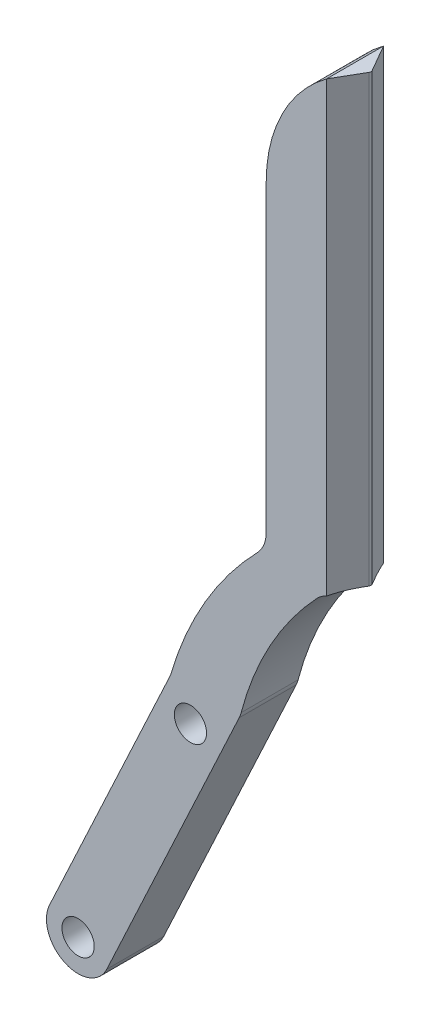
from build123d import *

# Parameters (mm, degrees)
SKETCH1_R           = 2.55
BOSS_EXTRUDE1_DEPTH = 9
SKETCH2_W           = 1.5
SKETCH2_H           = 71.301363943
CUT_EXTRUDE1_DEPTH  = 10
BOSS_EXTRUDE2_DEPTH = 70.2819
FILLET1_R           = 0.5
FILLET2_R           = 5


with BuildPart() as part:
    # Sketch1 → Boss-Extrude1 (new body)
    with BuildSketch(Plane.XY):
        with BuildLine():
            Line((-11.03377919, 0), (-30.17656458, -41.051835747))
            ThreePointArc((-30.17656458, -41.051835747), (-27.758116953, -47.696465991), (-21.113486709, -45.278018364))
            Line((-21.113486709, -45.278018364), (0, 0))
            ThreePointArc((0, 0), (5.686222606, 13.627582704), (15.104941349, 25))
            Line((15.104941349, 25), (15.104941349, 94.9))
            ThreePointArc((15.104941349, 94.9), (7.014188798, 86.377107313), (4.071162159, 75))
            Line((4.071162159, 75), (4.071162159, 25))
            ThreePointArc((4.071162159, 25), (-5.128820408, 13.495422821), (-11.03377919, 0))
        make_face()
        with Locations((-25.645025645, -43.164927056)):
            Circle(SKETCH1_R, mode=Mode.SUBTRACT)
        with Locations((-7.895058651, -5.1)):
            Circle(SKETCH1_R, mode=Mode.SUBTRACT)
    extrude(amount=BOSS_EXTRUDE1_DEPTH)

    # Sketch2 → Cut-Extrude1 (cut, through all)
    with BuildSketch(Plane.XY.offset(9)):
        with Locations((14.354941349, 59.249318028)):
            Rectangle(SKETCH2_W, SKETCH2_H)
    extrude(amount=-CUT_EXTRUDE1_DEPTH, mode=Mode.SUBTRACT)

    # Sketch4 → Boss-Extrude2 (add)
    with BuildSketch(Plane(origin=(0, 93.880535659, 0), x_dir=(0, 0, -1), z_dir=(0, -1, 0))):
        Polygon((0, 13.604941349), (-4.5, 16.20301756), (-9, 13.604941349), align=None)
    extrude(amount=BOSS_EXTRUDE2_DEPTH)

    # Fillet1
    fillet1_edges = [part.edges().sort_by_distance(p)[0] for p in [
        (16.20301756, 58.739585659, 4.5),
    ]]
    fillet(fillet1_edges, radius=FILLET1_R)

    # Fillet2
    fillet2_edges = [part.edges().sort_by_distance(p)[0] for p in [
        (0, 0, 4.5),
        (-11.03377919, 0, 4.5),
        (4.071162159, 25, 4.5),
        (13.604941349, 23.598636057, 4.5),
    ]]
    fillet(fillet2_edges, radius=FILLET2_R)


solid = part.part
